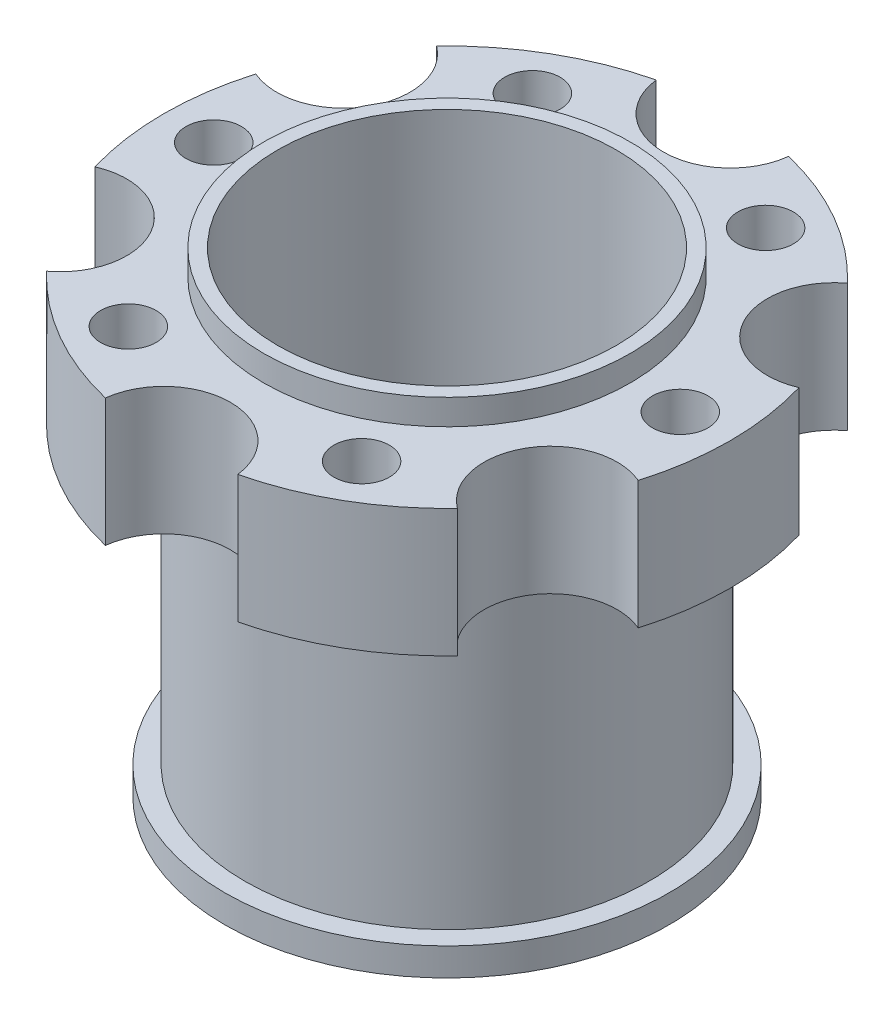
from build123d import *

# Parameters (mm, degrees)
EXTRUDE_1_DEPTH     = 11.5
SKETCH_2_R          = 16.5
SKETCH_2_R_2        = 15.25
EXTRUDE_2_DEPTH     = 2.3
SKETCH_3_R          = 15.25
CUT_EXTRUDE_2_DEPTH = 12.5
SKETCH_4_R          = 18.2
SKETCH_4_R_2        = 15.25
EXTRUDE_3_DEPTH     = 26.5
SKETCH_5_R          = 20
SKETCH_5_R_2        = 18.2
EXTRUDE_4_DEPTH     = 2.5
SKETCH_7_R          = 2.5
CUT_EXTRUDE_4_DEPTH = 19


with BuildPart() as part:
    # ｽｹｯﾁ1 → ﾎﾞｽ - 押し出し1 (new body)
    with BuildSketch(Plane(origin=(0, 0, 0), x_dir=(1, 0, 0), z_dir=(0, 1, 0))):
        with BuildLine():
            ThreePointArc((-5.958332829, 24.794117647), (0, 19.5), (5.958332829, 24.794117647))
            ThreePointArc((5.958332829, 24.794117647), (12.75, 22.083647797), (18.493169332, 17.557126418))
            ThreePointArc((18.493169332, 17.557126418), (16.887495374, 9.75), (24.451502161, 7.236991229))
            ThreePointArc((24.451502161, 7.236991229), (25.5, 0), (24.451502161, -7.236991229))
            ThreePointArc((24.451502161, -7.236991229), (16.887495374, -9.75), (18.493169332, -17.557126418))
            ThreePointArc((18.493169332, -17.557126418), (12.75, -22.083647797), (5.958332829, -24.794117647))
            ThreePointArc((5.958332829, -24.794117647), (0, -19.5), (-5.958332829, -24.794117647))
            ThreePointArc((-5.958332829, -24.794117647), (-12.75, -22.083647797), (-18.493169332, -17.557126418))
            ThreePointArc((-18.493169332, -17.557126418), (-16.887495374, -9.75), (-24.451502161, -7.236991229))
            ThreePointArc((-24.451502161, -7.236991229), (-25.5, 0), (-24.451502161, 7.236991229))
            ThreePointArc((-24.451502161, 7.236991229), (-16.887495374, 9.75), (-18.493169332, 17.557126418))
            ThreePointArc((-18.493169332, 17.557126418), (-12.75, 22.083647797), (-5.958332829, 24.794117647))
        make_face()
    extrude(amount=EXTRUDE_1_DEPTH)

    # ｽｹｯﾁ2 → ﾎﾞｽ - 押し出し2 (add)
    with BuildSketch(Plane(origin=(0, 11.5, 0), x_dir=(1, 0, 0), z_dir=(0, 1, 0))):
        Circle(SKETCH_2_R)
        Circle(SKETCH_2_R_2, mode=Mode.SUBTRACT)
    extrude(amount=EXTRUDE_2_DEPTH)

    # ｽｹｯﾁ3 → ｶｯﾄ - 押し出し2 (cut, through all)
    with BuildSketch(Plane(origin=(0, 11.5, 0), x_dir=(1, 0, 0), z_dir=(0, 1, 0))):
        Circle(SKETCH_3_R)
    extrude(amount=-CUT_EXTRUDE_2_DEPTH, mode=Mode.SUBTRACT)

    # ｽｹｯﾁ4 → ﾎﾞｽ - 押し出し3 (add)
    with BuildSketch(Plane.XZ):
        Circle(SKETCH_4_R)
        Circle(SKETCH_4_R_2, mode=Mode.SUBTRACT)
    extrude(amount=EXTRUDE_3_DEPTH)

    # ｽｹｯﾁ7 → ｶｯﾄ - 押し出し4 (cut)
    with BuildSketch(Plane(origin=(0, 11.5, 0), x_dir=(1, 0, 0), z_dir=(0, 1, 0))):
        with Locations((21, 0)):
            Circle(SKETCH_7_R)
        with Locations((10.5, -18.186533479)):
            Circle(SKETCH_7_R)
        with Locations((-10.5, -18.186533479)):
            Circle(SKETCH_7_R)
        with Locations((-21, 0)):
            Circle(SKETCH_7_R)
        with Locations((-10.5, 18.186533479)):
            Circle(SKETCH_7_R)
        with Locations((10.5, 18.186533479)):
            Circle(SKETCH_7_R)
    extrude(amount=-CUT_EXTRUDE_4_DEPTH, mode=Mode.SUBTRACT)


with BuildPart() as body_2:
    # ｽｹｯﾁ5 → ﾎﾞｽ - 押し出し4 (new body)
    with BuildSketch(Plane.XZ.offset(26.5)):
        Circle(SKETCH_5_R)
        Circle(SKETCH_5_R_2, mode=Mode.SUBTRACT)
    extrude(amount=EXTRUDE_4_DEPTH)


solid = Compound([part.part, body_2.part])
